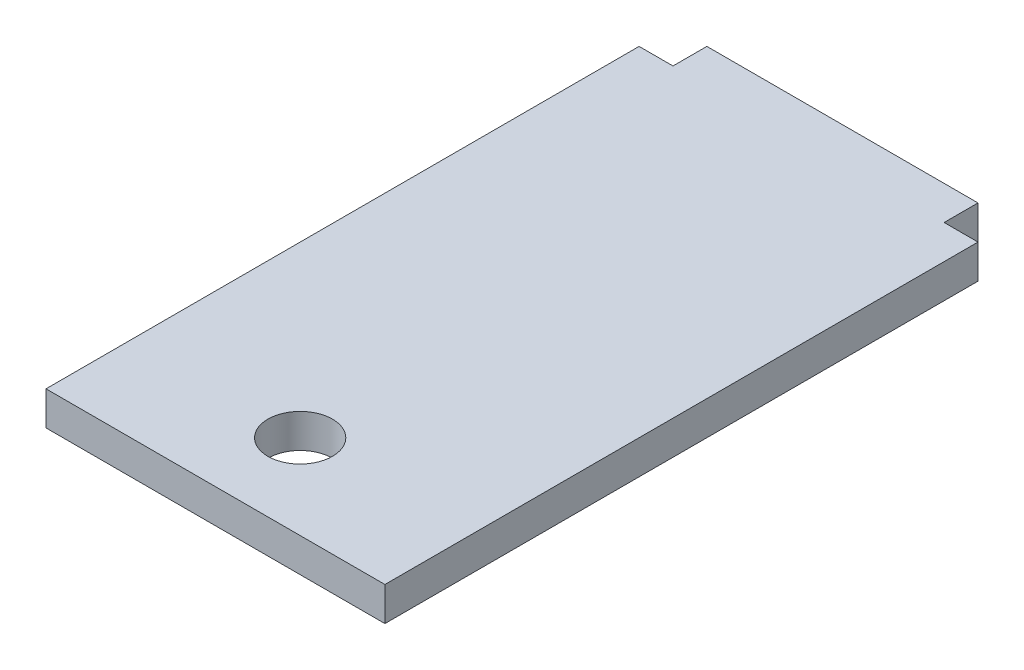
from build123d import *

# Parameters (mm, degrees)
SKETCH1_R    = 4.7625
HAMMER_DEPTH = 5


with BuildPart() as part:
    # Sketch1 → Hammer (new body)
    with BuildSketch(Plane(origin=(0, 0, 0), x_dir=(1, 0, 0), z_dir=(0, 1, 0))):
        Polygon((0, 87.5), (5, 87.5), (5, 92.5), (45, 92.5), (45, 87.5), (50, 87.5), (50, 0), (0, 0), align=None)
        with Locations((25, 12.5)):
            Circle(SKETCH1_R, mode=Mode.SUBTRACT)
    extrude(amount=HAMMER_DEPTH)


solid = part.part
